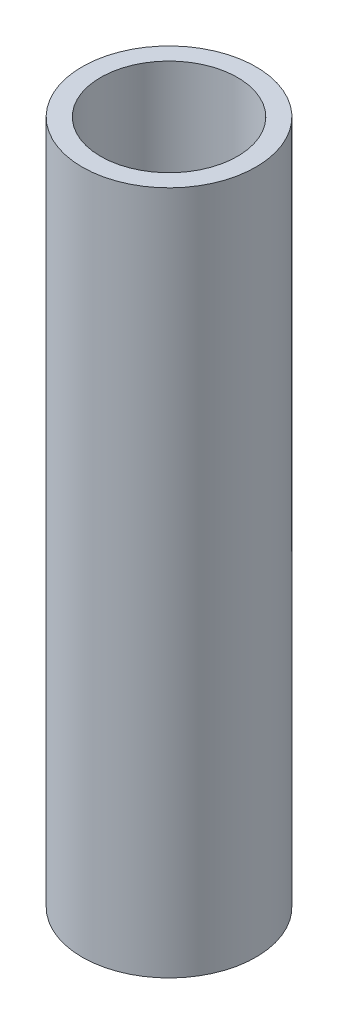
from build123d import *

# Parameters (mm, degrees)
ESQUISSE1_R        = 6.35
ESQUISSE1_R_2      = 5
BOSS_EXTRU_1_DEPTH = 50


with BuildPart() as part:
    # Esquisse1 → Boss.-Extru.1 (new body)
    with BuildSketch(Plane(origin=(0, 0, 0), x_dir=(1, 0, 0), z_dir=(0, 1, 0))):
        Circle(ESQUISSE1_R)
        Circle(ESQUISSE1_R_2, mode=Mode.SUBTRACT)
    extrude(amount=BOSS_EXTRU_1_DEPTH)


solid = part.part
